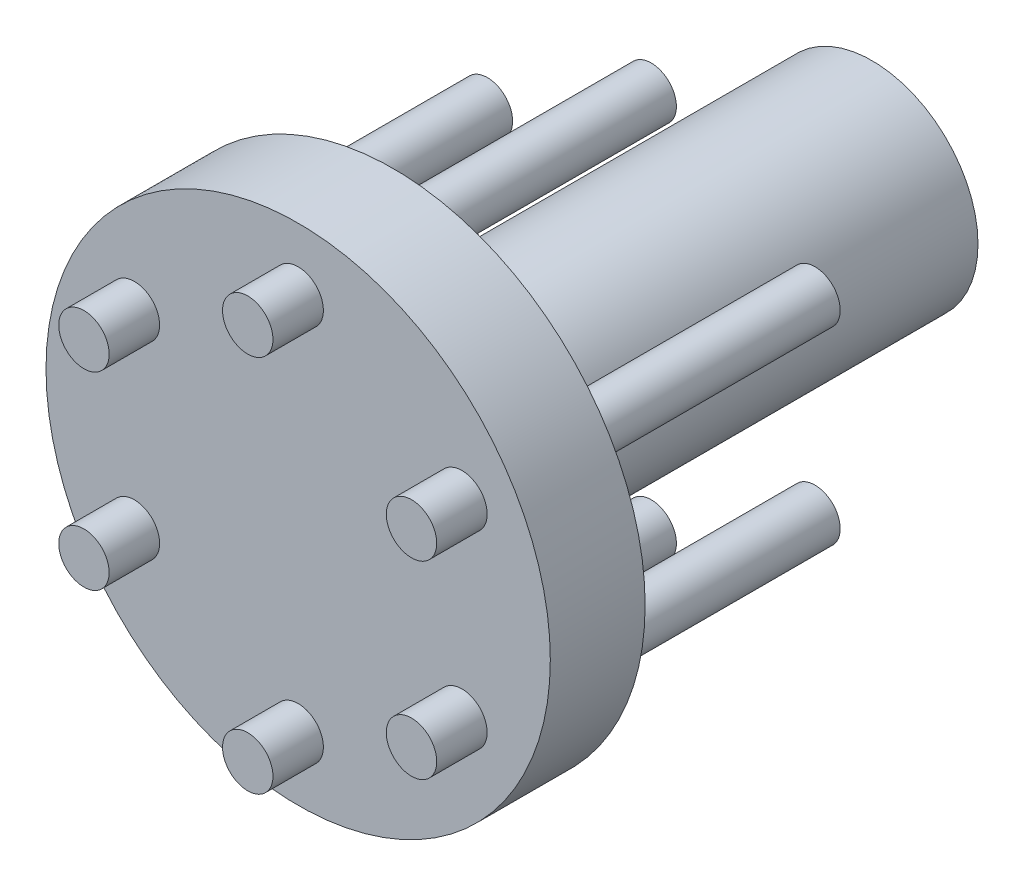
from build123d import *

# Parameters (mm, degrees)
SKETCH1_R                = 12.7
BOSS_EXTRUDE1_DEPTH      = 4.7752
SKETCH2_R                = 5.334
BOSS_EXTRUDE2_DEPTH      = 24.13
SKETCH3_R                = 1.27
BOSS_EXTRUDE3_DEPTH      = 2.54
BOSS_EXTRUDE3_DEPTH_BACK = 17.78
SKETCH6_W                = 2.54
SKETCH6_H                = 1.27
BOSS_EXTRUDE4_DEPTH      = 2.54


with BuildPart() as part:
    # Sketch1 → Boss-Extrude1 (new body)
    with BuildSketch(Plane.XY):
        Circle(SKETCH1_R)
    extrude(amount=BOSS_EXTRUDE1_DEPTH)

    # Sketch2 → Boss-Extrude2 (add)
    with BuildSketch(Plane(origin=(0, 0, 0), x_dir=(-1, 0, 0), z_dir=(0, 0, -1))):
        Circle(SKETCH2_R)
    extrude(amount=BOSS_EXTRUDE2_DEPTH)

    # Sketch3 → Boss-Extrude3 (add, two sides)
    with BuildSketch(Plane.XY.offset(4.7752)) as boss_extrude3_sk:
        with Locations((0, 9.525)):
            Circle(SKETCH3_R)
        with Locations((8.248891971, 4.7625)):
            Circle(SKETCH3_R)
        with Locations((8.248891971, -4.7625)):
            Circle(SKETCH3_R)
        with Locations((0, -9.525)):
            Circle(SKETCH3_R)
        with Locations((-8.248891971, -4.7625)):
            Circle(SKETCH3_R)
        with Locations((-8.248891971, 4.7625)):
            Circle(SKETCH3_R)
    extrude(amount=BOSS_EXTRUDE3_DEPTH)
    extrude(boss_extrude3_sk.sketch, amount=-BOSS_EXTRUDE3_DEPTH_BACK)

    # Sketch6 → Boss-Extrude4 (add)
    with BuildSketch(Plane(origin=(0, 0, 0), x_dir=(-1, 0, 0), z_dir=(0, 0, -1))):
        Polygon((1.482073869, 3.837027241), (2.581926131, 3.202027241), (3.851926131, 5.401731767), (2.752073869, 6.036731767), align=None)
        with Locations((5.334, 0)):
            Rectangle(SKETCH6_W, SKETCH6_H)
        Polygon((2.581926131, -3.202027241), (3.851926131, -5.401731767), (2.752073869, -6.036731767), (1.482073869, -3.837027241), align=None)
        Polygon((-1.482073869, -3.837027241), (-2.752073869, -6.036731767), (-3.851926131, -5.401731767), (-2.581926131, -3.202027241), align=None)
        with Locations((-5.334, 0)):
            Rectangle(SKETCH6_W, SKETCH6_H)
        Polygon((-2.581926131, 3.202027241), (-3.851926131, 5.401731767), (-2.752073869, 6.036731767), (-1.482073869, 3.837027241), align=None)
    extrude(amount=BOSS_EXTRUDE4_DEPTH)


solid = part.part
